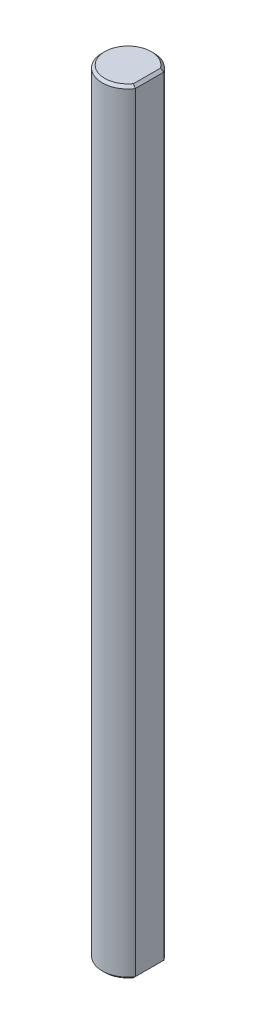
from build123d import *

# Parameters (mm, degrees)
BOSS_EXTRUDE1_DEPTH = 90
CHAMFER1_SIZE       = 0.3


with BuildPart() as part:
    # Sketch1 → Boss-Extrude1 (new body)
    with BuildSketch(Plane(origin=(0, 0, 0), x_dir=(1, 0, 0), z_dir=(0, 1, 0))):
        with BuildLine():
            Line((2.5, 1.658312395), (2.5, -1.658312395))
            ThreePointArc((2.5, -1.658312395), (-3, 0), (2.5, 1.658312395))
        make_face()
    extrude(amount=BOSS_EXTRUDE1_DEPTH)

    # Chamfer1
    chamfer1_edges = [part.edges().sort_by_distance(p)[0] for p in [
        (2.5, 0, 0),
        (-3, 0, 0),
        (-3, 90, 0),
        (2.5, 90, 0),
    ]]
    chamfer(chamfer1_edges, length=CHAMFER1_SIZE)


solid = part.part
